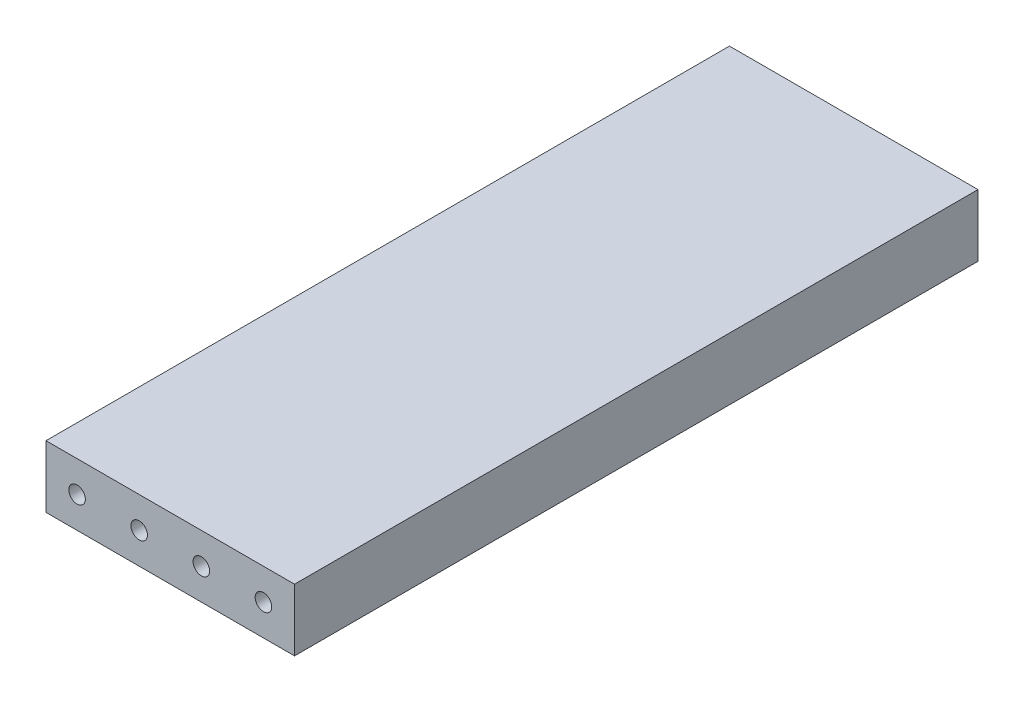
from build123d import *

# Parameters (mm, degrees)
SKETCH1_W           = 120
SKETCH1_H           = 30
BOSS_EXTRUDE1_DEPTH = 165
SKETCH2_R           = 4
CUT_EXTRUDE1_DEPTH  = 331


with BuildPart() as part:
    # Sketch1 → Boss-Extrude1 (new body, symmetric)
    with BuildSketch(Plane.XY):
        Rectangle(SKETCH1_W, SKETCH1_H)
    extrude(amount=BOSS_EXTRUDE1_DEPTH, both=True)

    # Sketch2 → Cut-Extrude1 (cut, through all)
    with BuildSketch(Plane(origin=(0, 0, -165), x_dir=(-1, 0, 0), z_dir=(0, 0, -1))):
        with Locations((-45, 0)):
            Circle(SKETCH2_R)
        with Locations((-15, 0)):
            Circle(SKETCH2_R)
        with Locations((15, 0)):
            Circle(SKETCH2_R)
        with Locations((45, 0)):
            Circle(SKETCH2_R)
    extrude(amount=-CUT_EXTRUDE1_DEPTH, mode=Mode.SUBTRACT)


solid = part.part
